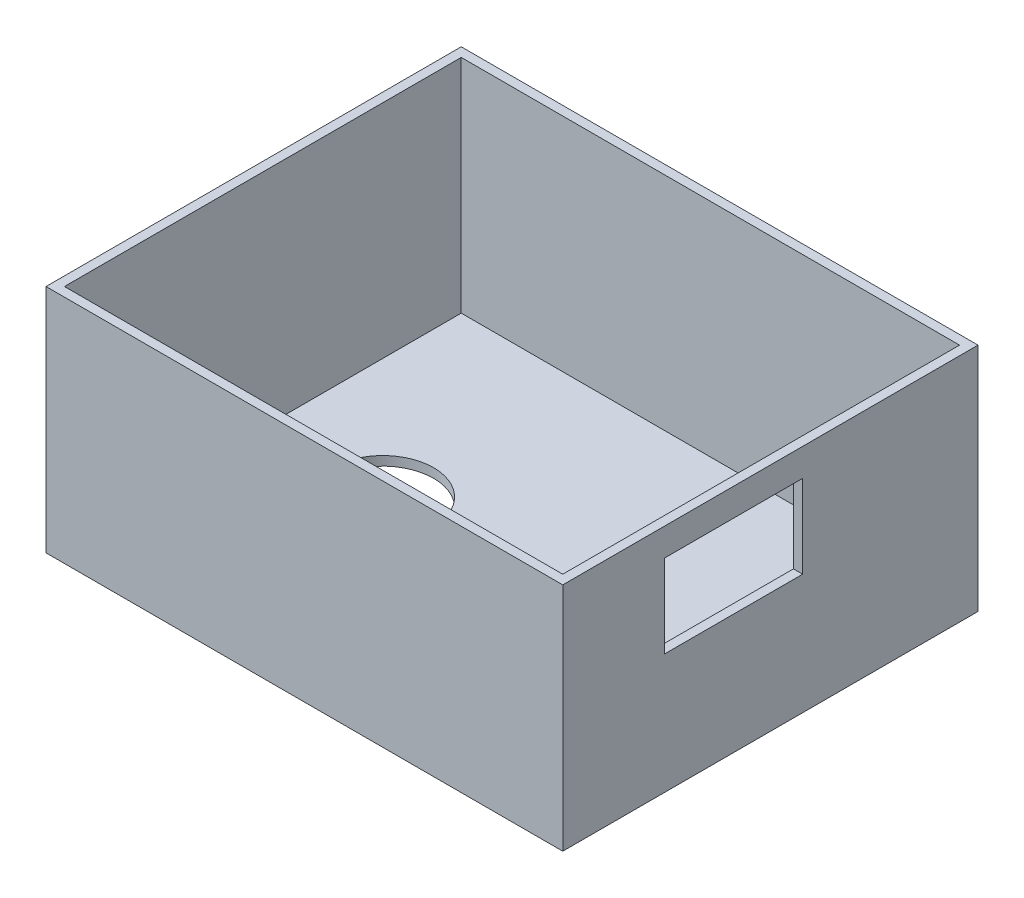
from build123d import *

# Parameters (mm, degrees)
SKETCH1_W           = 56
SKETCH1_H           = 45
BOSS_EXTRUDE1_DEPTH = 25
SKETCH2_R           = 5.5
CUT_EXTRUDE1_DEPTH  = 15
SKETCH3_W           = 54
SKETCH3_H           = 43
CUT_EXTRUDE2_DEPTH  = 24
SKETCH4_W           = 15
SKETCH4_H           = 9
CUT_EXTRUDE3_DEPTH  = 24


with BuildPart() as part:
    # Sketch1 → Boss-Extrude1 (new body)
    with BuildSketch(Plane(origin=(0, 0, 0), x_dir=(1, 0, 0), z_dir=(0, 1, 0))):
        Rectangle(SKETCH1_W, SKETCH1_H)
    extrude(amount=BOSS_EXTRUDE1_DEPTH)

    # Sketch2 → Cut-Extrude1 (cut)
    with BuildSketch(Plane.XZ):
        with Locations((-14, 0)):
            Circle(SKETCH2_R)
    extrude(amount=-CUT_EXTRUDE1_DEPTH, mode=Mode.SUBTRACT)

    # Sketch3 → Cut-Extrude2 (cut)
    with BuildSketch(Plane(origin=(0, 25, 0), x_dir=(1, 0, 0), z_dir=(0, 1, 0))):
        Rectangle(SKETCH3_W, SKETCH3_H)
    extrude(amount=-CUT_EXTRUDE2_DEPTH, mode=Mode.SUBTRACT)

    # Sketch4 → Cut-Extrude3 (cut)
    with BuildSketch(Plane(origin=(28, 0, 0), x_dir=(0, 0, -1), z_dir=(1, 0, 0))):
        with Locations((-4, 17.5)):
            Rectangle(SKETCH4_W, SKETCH4_H)
    extrude(amount=-CUT_EXTRUDE3_DEPTH, mode=Mode.SUBTRACT)


solid = part.part
